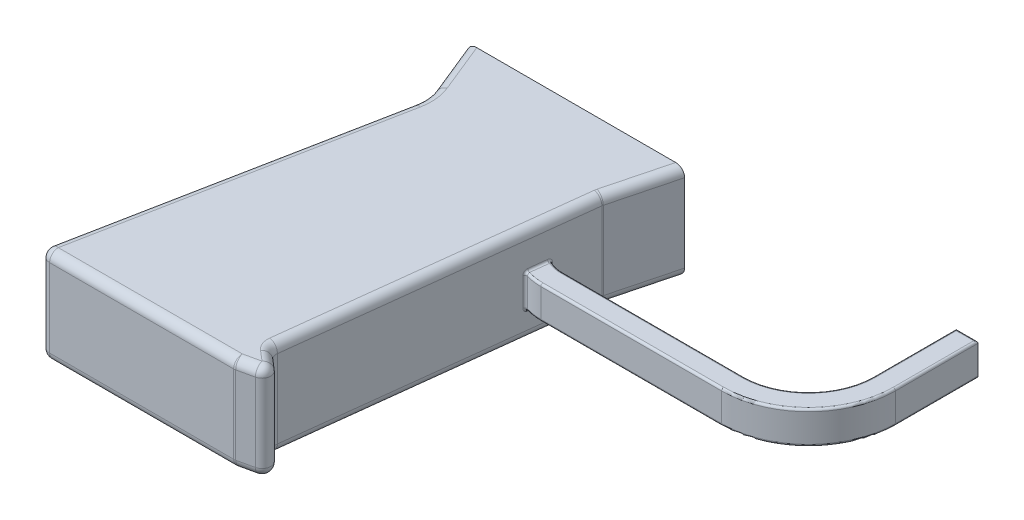
from build123d import *

# Parameters (mm, degrees)
BOSS_EXTRUDE1_DEPTH = 22
FILLET1_R           = 10
FILLET1_2_R         = 2
BOSS_EXTRUDE2_START = 6.25
BOSS_EXTRUDE2_DEPTH = 7.5
FILLET2_R           = 0.5


with BuildPart() as part:
    # Sketch1 → Boss-Extrude1 (new body)
    with BuildSketch(Plane(origin=(0, 0, 0), x_dir=(1, 0, 0), z_dir=(0, 1, 0))):
        Polygon((0, 0), (50, 0), (46.103209795, -15), (38.079497445, -82.972851485), (44.273841657, -88.266236279), (36.436917163, -90), (-8.563082837, -90), (6.103209795, -15), align=None)
    extrude(amount=BOSS_EXTRUDE1_DEPTH)

    # Fillet1
    fillet1_edges = [part.edges().sort_by_distance(p)[0] for p in [
        (6.103209795, 11, 15),
    ]]
    fillet(fillet1_edges, radius=FILLET1_R)

    # Fillet1 2
    fillet1_2_edges = [part.edges().sort_by_distance(p)[0] for p in [
        (40.35537941, 0, 89.133118139),
        (13.936917163, 0, 90),
        (-1.229936521, 0, 52.5),
        (3.051604897, 0, 7.5),
        (13.936917163, 22, 90),
        (46.103209795, 11, 15),
        (38.079497445, 11, 82.972851485),
        (44.273841657, 11, 88.266236279),
        (36.436917163, 11, 90),
        (-8.563082837, 11, 90),
        (40.35537941, 22, 89.133118139),
        (41.176669551, 22, 85.619543882),
        (42.09135362, 22, 48.986425743),
        (48.051604897, 22, 7.5),
        (3.051604897, 22, 7.5),
        (-1.229936521, 22, 52.5),
        (48.051604897, 0, 7.5),
        (42.09135362, 0, 48.986425743),
        (41.176669551, 0, 85.619543882),
    ]]
    fillet(fillet1_2_edges, radius=FILLET1_2_R)

    # Sketch2 → Boss-Extrude2 (add)
    with BuildSketch(Plane(origin=(0, 0, 0), x_dir=(1, 0, 0), z_dir=(0, 1, 0)).offset(BOSS_EXTRUDE2_START)):
        with BuildLine():
            Line((105, 7.5), (110, 7.5))
            Line((110, 7.5), (110, -11.5))
            ThreePointArc((110, -11.5), (104.142135624, -25.642135624), (90, -31.5))
            Line((90, -31.5), (48.388646792, -31.5))
            ThreePointArc((48.388646792, -31.5), (46.283857117, -31.321520216), (44.239173426, -30.791177667))
            Line((44.239173426, -30.791177667), (44.850427357, -25.612942101))
            ThreePointArc((44.850427357, -25.612942101), (46.564786293, -26.27485621), (48.388646792, -26.5))
            Line((48.388646792, -26.5), (90, -26.5))
            ThreePointArc((90, -26.5), (100.606601718, -22.106601718), (105, -11.5))
            Line((105, -11.5), (105, 7.5))
        make_face()
    extrude(amount=BOSS_EXTRUDE2_DEPTH)

    # Fillet2
    fillet2_edges = [part.edges().sort_by_distance(p)[0] for p in [
        (105, 6.25, 2),
        (100.606601718, 6.25, 22.106601718),
        (69.194323396, 6.25, 26.5),
        (46.564786293, 6.25, 26.27485621),
        (44.544800391, 6.25, 28.202059884),
        (44.850427357, 10, 25.612942101),
        (46.283857117, 6.25, 31.321520216),
        (44.239173426, 10, 30.791177667),
        (69.194323396, 6.25, 31.5),
        (104.142135624, 6.25, 25.642135624),
        (110, 6.25, 2),
        (107.5, 6.25, -7.5),
        (105, 13.75, 2),
        (100.606601718, 13.75, 22.106601718),
        (69.194323396, 13.75, 26.5),
        (46.564786293, 13.75, 26.27485621),
        (44.544800391, 13.75, 28.202059884),
        (46.283857117, 13.75, 31.321520216),
        (69.194323396, 13.75, 31.5),
        (104.142135624, 13.75, 25.642135624),
        (110, 13.75, 2),
        (107.5, 13.75, -7.5),
    ]]
    fillet(fillet2_edges, radius=FILLET2_R)


solid = part.part
